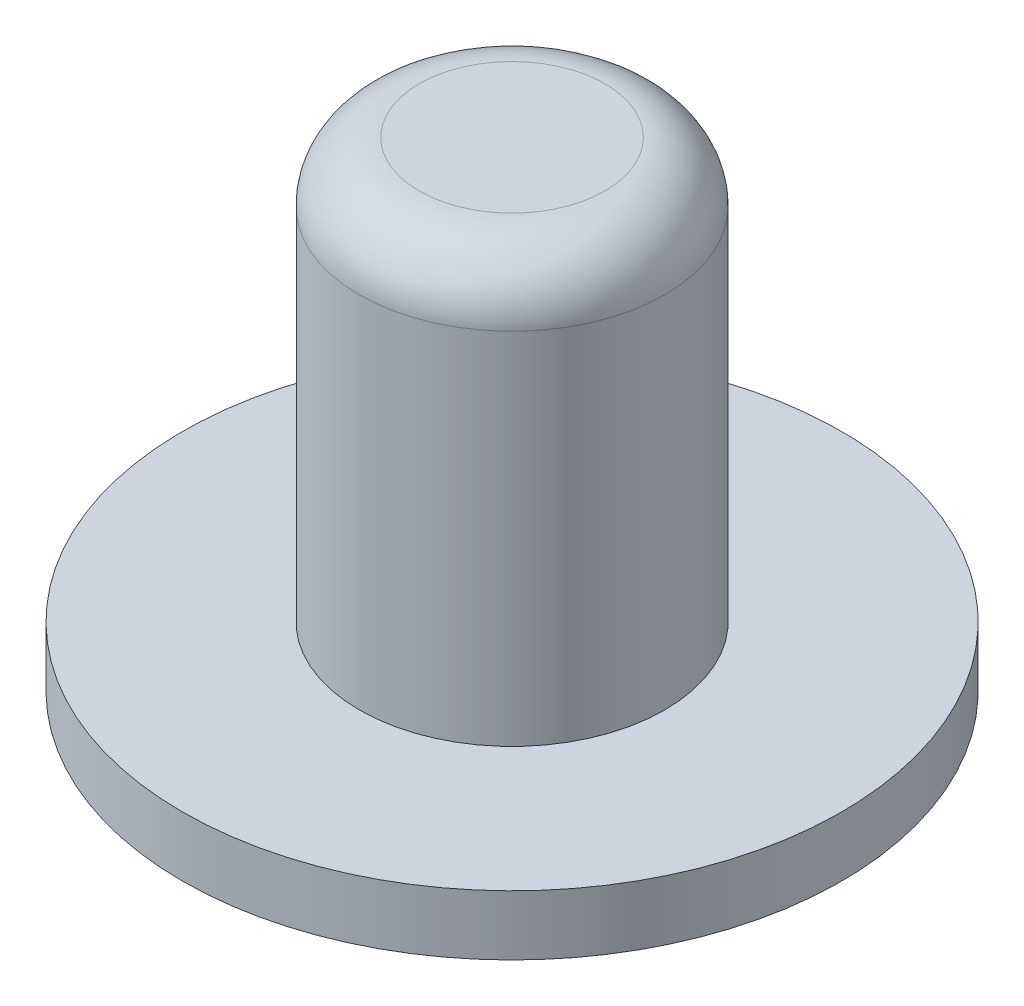
from build123d import *

# Parameters (mm, degrees)
SKETCH1_R           = 2.55
BOSS_EXTRUDE1_DEPTH = 7
SKETCH1_3_R         = 5.5
BOSS_EXTRUDE2_DEPTH = 1
FILLET1_R           = 1


with BuildPart() as part:
    # Sketch1 → Boss-Extrude1 (new body)
    with BuildSketch(Plane(origin=(0, 0, 0), x_dir=(1, 0, 0), z_dir=(0, 1, 0))):
        Circle(SKETCH1_R)
    extrude(amount=BOSS_EXTRUDE1_DEPTH)

    # Sketch1_3 → Boss-Extrude2 (add)
    with BuildSketch(Plane(origin=(0, 0, 0), x_dir=(1, 0, 0), z_dir=(0, 1, 0))):
        Circle(SKETCH1_3_R)
    extrude(amount=-BOSS_EXTRUDE2_DEPTH)

    # Fillet1
    fillet1_edges = [part.edges().sort_by_distance(p)[0] for p in [
        (-2.55, 7, 0),
    ]]
    fillet(fillet1_edges, radius=FILLET1_R)


solid = part.part
